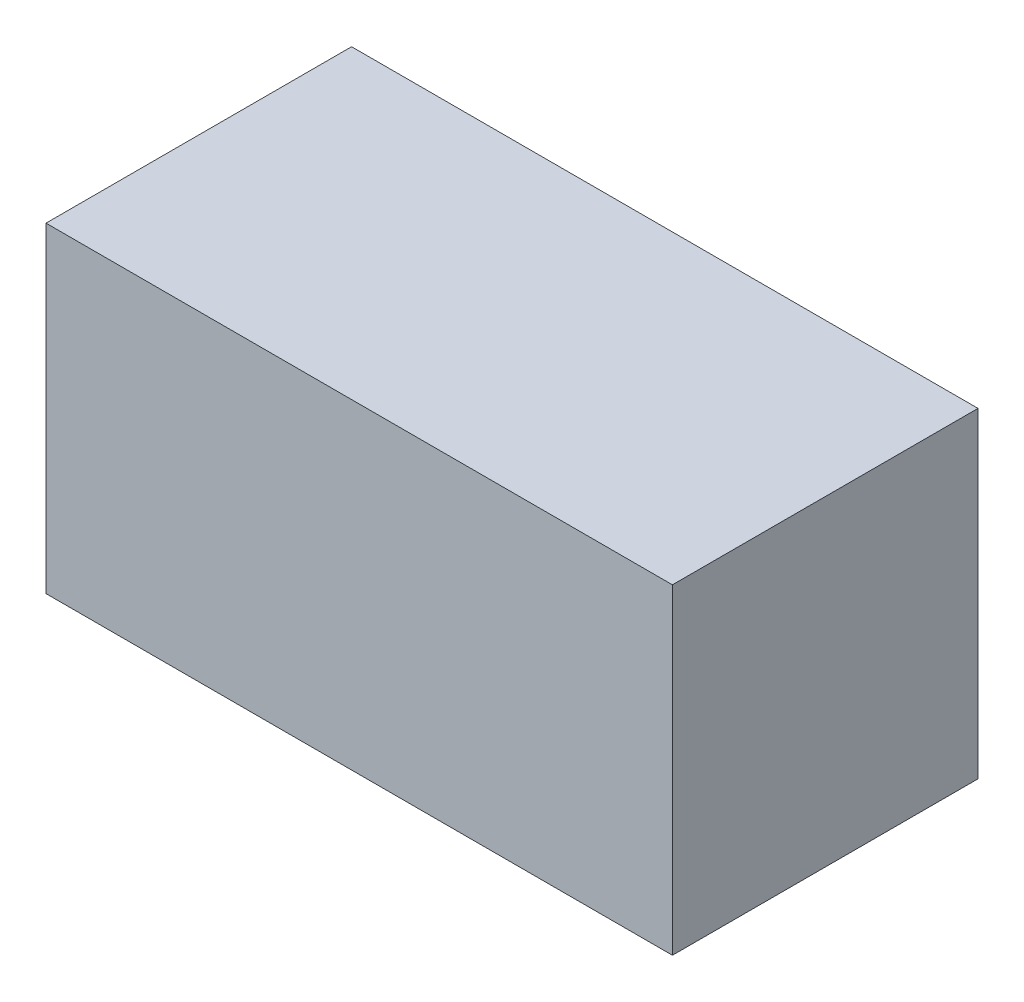
from build123d import *

# Parameters (mm, degrees)
SKETCH1_W           = 41
SKETCH1_H           = 21
BOSS_EXTRUDE1_DEPTH = 20


with BuildPart() as part:
    # Sketch1 → Boss-Extrude1 (new body)
    with BuildSketch(Plane.XY):
        with Locations((20.5, 10.5)):
            Rectangle(SKETCH1_W, SKETCH1_H)
    extrude(amount=BOSS_EXTRUDE1_DEPTH)


solid = part.part
